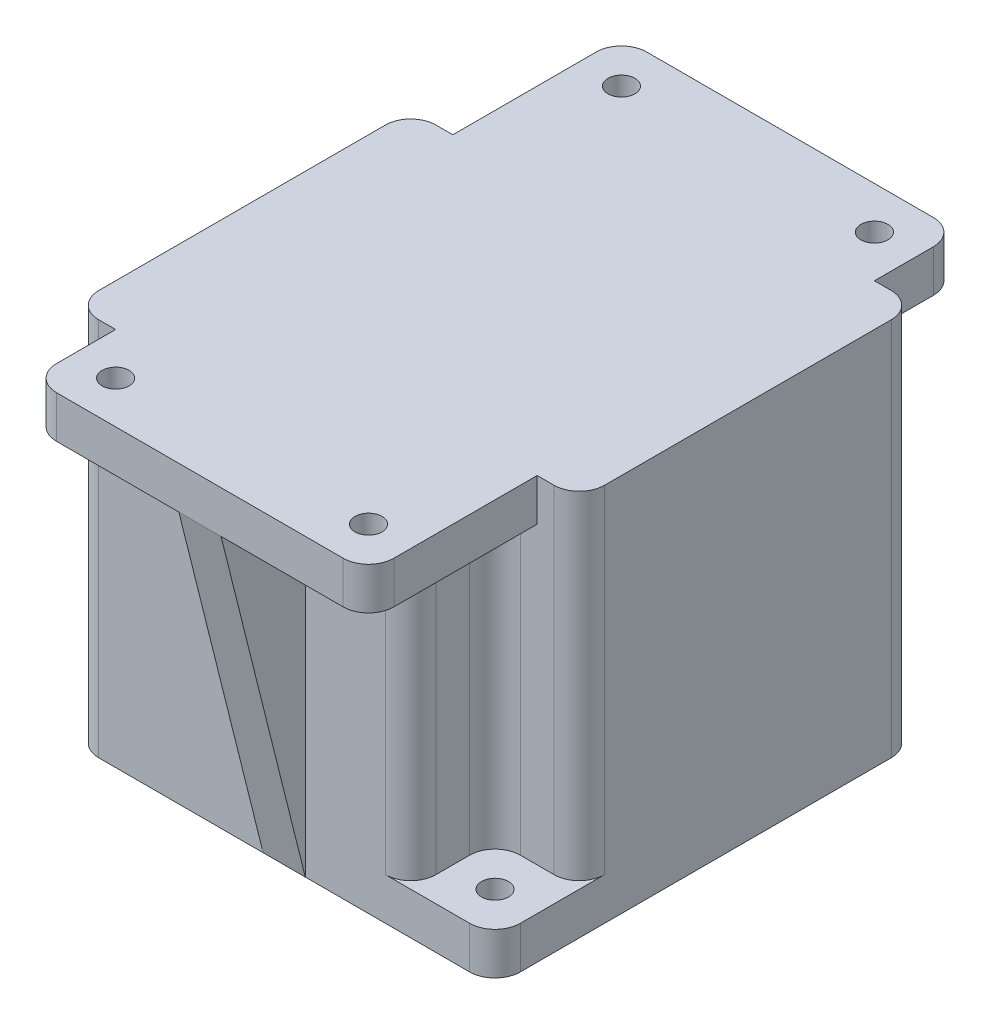
from build123d import *

# Parameters (mm, degrees)
ESQUISSE1_W             = 50
ESQUISSE1_H             = 50
ESQUISSE1_R             = 1.6
BOSS_EXTRU_1_DEPTH      = 45
CONG_1_R                = 3
ESQUISSE2_W             = 10
ESQUISSE2_H             = 10
ENL_V_MAT_EXTRU_1_DEPTH = 40
ESQUISSE4_W             = 40
ESQUISSE4_H             = 70
ESQUISSE4_R             = 1.6
BOSS_EXTRU_2_DEPTH      = 5
CONG_3_R                = 3
CONG_4_R                = 3
ENL_V_MAT_EXTRU_3_DEPTH = 2.5
BOSS_EXTRU_3_DEPTH      = 2.5
BOSS_EXTRU_3_DEPTH_BACK = 2.5


with BuildPart() as part:
    # Esquisse1 → Boss.-Extru.1 (new body)
    with BuildSketch(Plane(origin=(0, 0, 0), x_dir=(1, 0, 0), z_dir=(0, 1, 0))):
        Rectangle(ESQUISSE1_W, ESQUISSE1_H)
        with Locations((-20, 20)):
            Circle(ESQUISSE1_R, mode=Mode.SUBTRACT)
        with Locations((20, -20)):
            Circle(ESQUISSE1_R, mode=Mode.SUBTRACT)
    extrude(amount=BOSS_EXTRU_1_DEPTH)

    # Congé1
    cong_1_edges = [part.edges().sort_by_distance(p)[0] for p in [
        (25, 22.5, 25),
        (-25, 22.5, 25),
        (-25, 22.5, -25),
        (25, 22.5, -25),
    ]]
    fillet(cong_1_edges, radius=CONG_1_R)

    # Esquisse2 → Enlèv. mat.-Extru.1 (cut)
    with BuildSketch(Plane(origin=(0, 45, 0), x_dir=(1, 0, 0), z_dir=(0, 1, 0))):
        with Locations((-20, 20)):
            Rectangle(ESQUISSE2_W, ESQUISSE2_H)
        with Locations((20, -20)):
            Rectangle(ESQUISSE2_W, ESQUISSE2_H)
    extrude(amount=-ENL_V_MAT_EXTRU_1_DEPTH, mode=Mode.SUBTRACT)

    # Esquisse4 → Boss.-Extru.2 (add)
    with BuildSketch(Plane(origin=(0, 45, 0), x_dir=(1, 0, 0), z_dir=(0, 1, 0))):
        Rectangle(ESQUISSE4_W, ESQUISSE4_H)
        with Locations((-15, 30)):
            Circle(ESQUISSE4_R, mode=Mode.SUBTRACT)
        with Locations((15, 30)):
            Circle(ESQUISSE4_R, mode=Mode.SUBTRACT)
        with Locations((15, -30)):
            Circle(ESQUISSE4_R, mode=Mode.SUBTRACT)
        with Locations((-15, -30)):
            Circle(ESQUISSE4_R, mode=Mode.SUBTRACT)
    extrude(amount=-BOSS_EXTRU_2_DEPTH)

    # Congé3
    cong_3_edges = [part.edges().sort_by_distance(p)[0] for p in [
        (-20, 42.5, -35),
        (20, 42.5, 35),
        (20, 42.5, -35),
        (-20, 42.5, 35),
    ]]
    fillet(cong_3_edges, radius=CONG_3_R)

    # Congé4
    cong_4_edges = [part.edges().sort_by_distance(p)[0] for p in [
        (-25, 25, -15),
        (-15, 22.5, -25),
        (-15, 22.5, -15),
        (25, 25, 15),
        (15, 22.5, 25),
        (15, 22.5, 15),
    ]]
    fillet(cong_4_edges, radius=CONG_4_R)

    # Esquisse5 → Enlèv. mat.-Extru.3 (cut)
    with BuildSketch(Plane.XZ.offset(-40)):
        Polygon((-13.554086217, 27.108172435), (-11.772646974, 29.806284285), (-13.218560756, 32.69811185), (-16.445913783, 32.891827565), (-18.227353026, 30.193715715), (-16.781439244, 27.30188815), align=None)
        Polygon((13.296009851, 26.592019703), (17.099402439, 26.820311095), (18.803392587, 30.228291392), (16.703990149, 33.407980297), (12.900597561, 33.179688905), (11.196607413, 29.771708608), align=None)
        Polygon((13.296009851, -26.592019703), (11.196607413, -29.771708608), (12.900597561, -33.179688905), (16.703990149, -33.407980297), (18.803392587, -30.228291392), (17.099402439, -26.820311095), align=None)
        Polygon((-13.296009851, -26.592019703), (-17.099402439, -26.820311095), (-18.803392587, -30.228291392), (-16.703990149, -33.407980297), (-12.900597561, -33.179688905), (-11.196607413, -29.771708608), align=None)
    extrude(amount=-ENL_V_MAT_EXTRU_3_DEPTH, mode=Mode.SUBTRACT)

    # Esquisse6 → Boss.-Extru.3 (add, two sides)
    with BuildSketch(Plane(origin=(0, 0, 0), x_dir=(0, 0, -1), z_dir=(1, 0, 0))) as boss_extru_3_sk:
        Polygon((-35, 40), (-25, 0), (-25, 40), align=None)
        Polygon((35, 40), (25, 0), (25, 40), align=None)
    extrude(amount=BOSS_EXTRU_3_DEPTH)
    extrude(boss_extru_3_sk.sketch, amount=-BOSS_EXTRU_3_DEPTH_BACK)


solid = part.part
